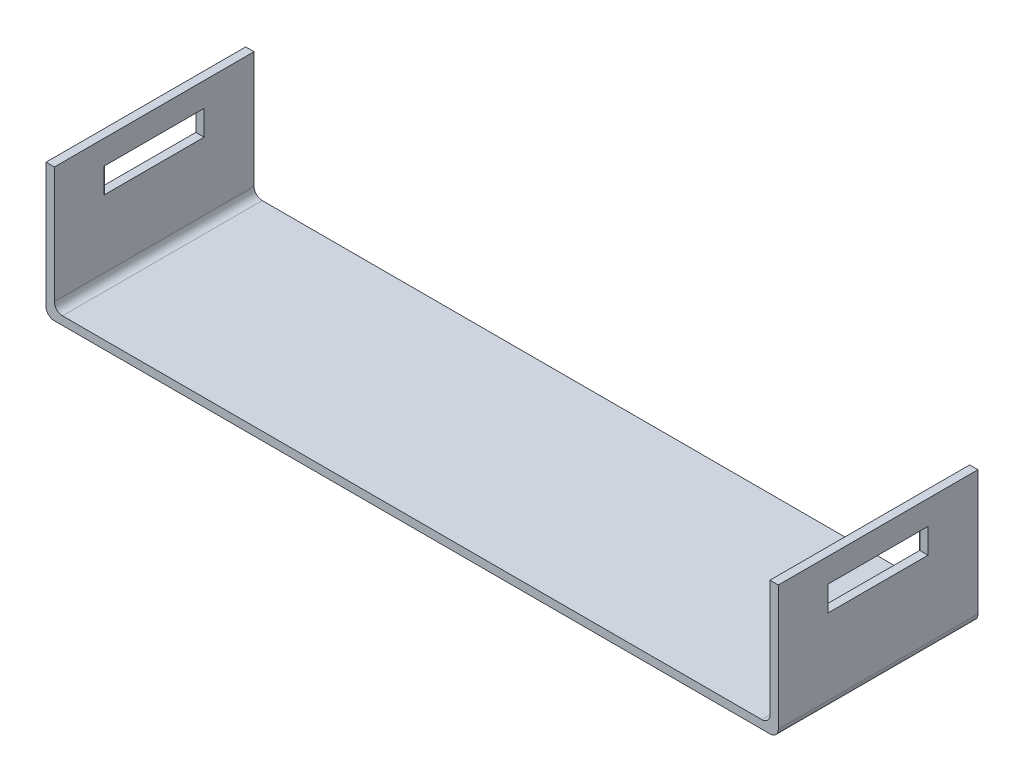
from build123d import *

# Parameters (mm, degrees)
BOSS_EXTRUDE1_DEPTH = 12
SKETCH2_W           = 6
SKETCH2_H           = 1.5
CUT_EXTRUDE1_DEPTH  = 45


with BuildPart() as part:
    # Sketch1 → Boss-Extrude1 (new body)
    with BuildSketch(Plane.XY):
        with BuildLine():
            Line((-21.5, 7.5), (-21.5, 0.49))
            ThreePointArc((-21.5, 0.49), (-21.356482323, 0.143517677), (-21.01, 0))
            Line((-21.01, 0), (0, 0))
            Line((0, 0), (21.01, 0))
            ThreePointArc((21.01, 0), (21.356482323, 0.143517677), (21.5, 0.49))
            Line((21.5, 0.49), (21.5, 7.5))
            Line((21.5, 7.5), (22, 7.5))
            Line((22, 7.5), (22, -0.01))
            ThreePointArc((22, -0.01), (21.856482323, -0.356482323), (21.51, -0.5))
            Line((21.51, -0.5), (-21.51, -0.5))
            ThreePointArc((-21.51, -0.5), (-21.856482323, -0.356482323), (-22, -0.01))
            Line((-22, -0.01), (-22, 7.5))
            Line((-22, 7.5), (-21.5, 7.5))
        make_face()
    extrude(amount=BOSS_EXTRUDE1_DEPTH)

    # Sketch2 → Cut-Extrude1 (cut, through all)
    with BuildSketch(Plane.ZY.offset(22)):
        with Locations((6, 5.3)):
            Rectangle(SKETCH2_W, SKETCH2_H)
    extrude(amount=-CUT_EXTRUDE1_DEPTH, mode=Mode.SUBTRACT)


solid = part.part
